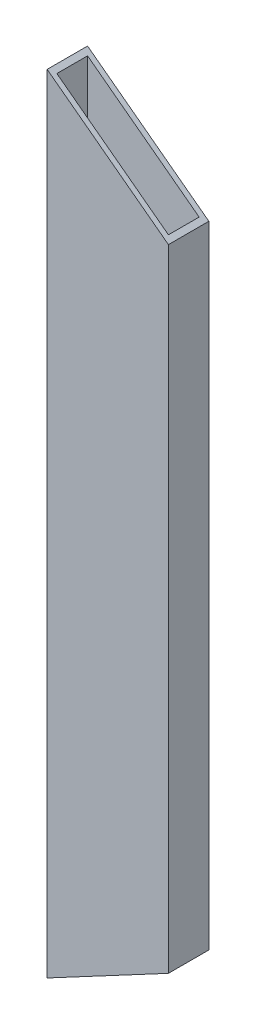
from build123d import *

# Parameters (mm, degrees)
SKETCH1_W           = 76.2
SKETCH1_H           = 25.4
SKETCH1_W_2         = 70.104
SKETCH1_H_2         = 19.304
BOSS_EXTRUDE1_DEPTH = 536.341159
CUT_EXTRUDE1_START  = -30.455423
SKETCH3_W           = 25.4
SKETCH3_H           = 76.2
CUT_EXTRUDE1_DEPTH  = 106.757864
CUT_EXTRUDE2_START  = -33.61888
SKETCH4_W           = 25.4
SKETCH4_H           = 76.2
CUT_EXTRUDE2_DEPTH  = 97.113932


with BuildPart() as part:
    # Sketch1 → Boss-Extrude1 (new body)
    with BuildSketch(Plane(origin=(0, 0, 0), x_dir=(1, 0, 0), z_dir=(0, 1, 0))):
        Rectangle(SKETCH1_W, SKETCH1_H)
        Rectangle(SKETCH1_W_2, SKETCH1_H_2, mode=Mode.SUBTRACT)
    extrude(amount=BOSS_EXTRUDE1_DEPTH)

    # Sketch3 → Cut-Extrude1 (cut)
    with BuildSketch(Plane(origin=(0, 536.341159245, 0), x_dir=(0, 0, -1), z_dir=(0.799354935, -0.600859125, 0)).offset(CUT_EXTRUDE1_START)):
        Rectangle(SKETCH3_W, SKETCH3_H)
    extrude(amount=CUT_EXTRUDE1_DEPTH, mode=Mode.SUBTRACT)

    # Sketch4 → Cut-Extrude2 (cut)
    with BuildSketch(Plane(origin=(0, 0, 0), x_dir=(0, 0, -1), z_dir=(0.882385297, 0.470527564, 0)).offset(CUT_EXTRUDE2_START)):
        Rectangle(SKETCH4_W, SKETCH4_H)
    extrude(amount=CUT_EXTRUDE2_DEPTH, mode=Mode.SUBTRACT)


solid = part.part
